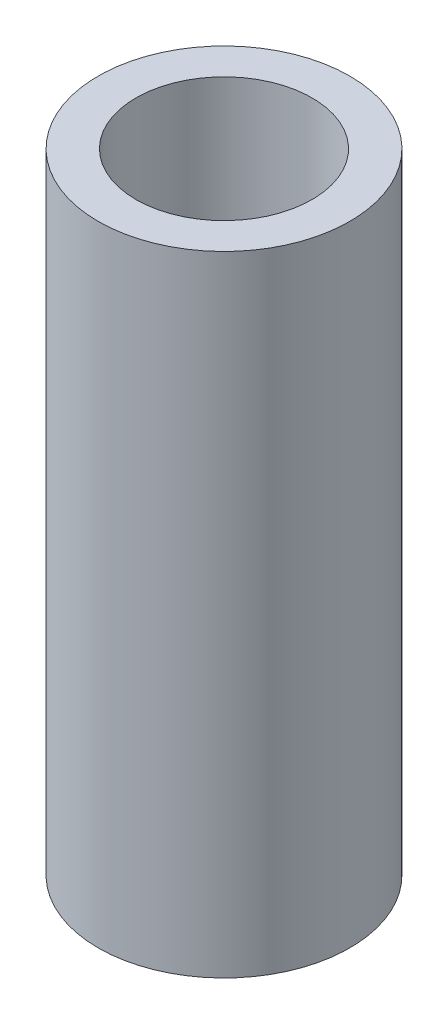
from build123d import *

# Parameters (mm, degrees)
SKETCH1_R           = 10
BOSS_EXTRUDE1_DEPTH = 50
SKETCH2_R           = 4
CUT_EXTRUDE1_DEPTH  = 51
SKETCH3_R           = 7
CUT_EXTRUDE2_DEPTH  = 35


with BuildPart() as part:
    # Sketch1 → Boss-Extrude1 (new body)
    with BuildSketch(Plane(origin=(0, 0, 0), x_dir=(1, 0, 0), z_dir=(0, 1, 0))):
        Circle(SKETCH1_R)
    extrude(amount=BOSS_EXTRUDE1_DEPTH)

    # Sketch2 → Cut-Extrude1 (cut, through all)
    with BuildSketch(Plane(origin=(0, 50, 0), x_dir=(1, 0, 0), z_dir=(0, 1, 0))):
        Circle(SKETCH2_R)
    extrude(amount=-CUT_EXTRUDE1_DEPTH, mode=Mode.SUBTRACT)

    # Sketch3 → Cut-Extrude2 (cut)
    with BuildSketch(Plane(origin=(0, 50, 0), x_dir=(1, 0, 0), z_dir=(0, 1, 0))):
        Circle(SKETCH3_R)
    extrude(amount=-CUT_EXTRUDE2_DEPTH, mode=Mode.SUBTRACT)


solid = part.part
